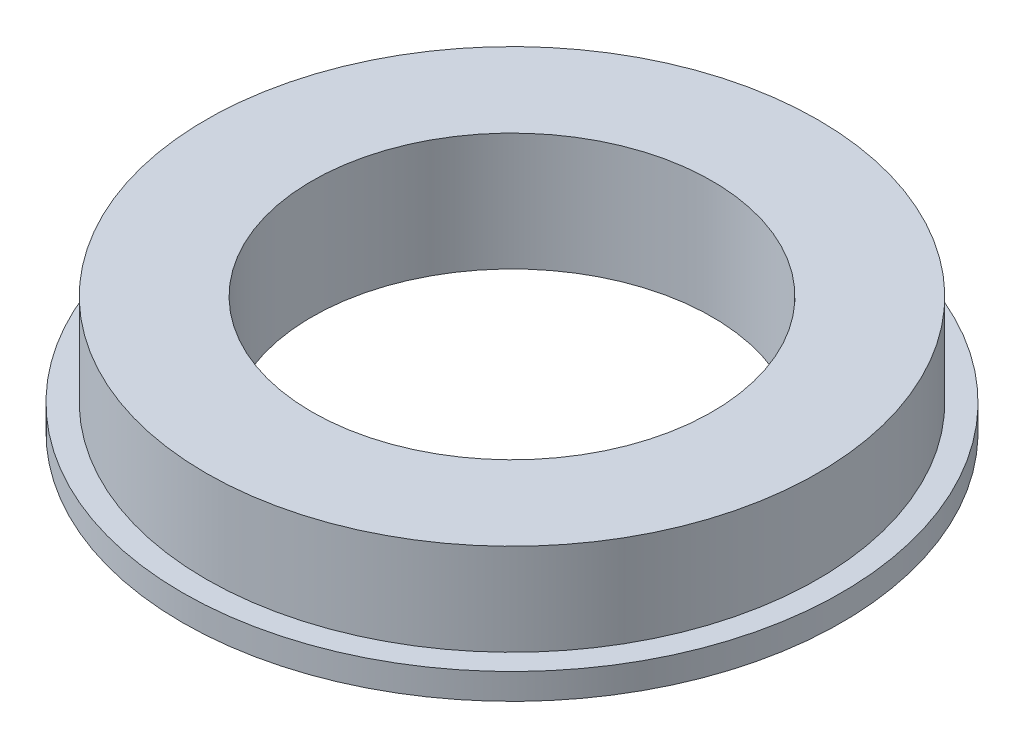
from build123d import *

# Parameters (mm, degrees)
SKETCH_2_R          = 14
EXTRUDE_1_DEPTH     = 1.1
SKETCH_3_R          = 13
EXTRUDE_2_DEPTH     = 3.9
SKETCH_4_R          = 8.5
CUT_EXTRUDE_1_DEPTH = 6


with BuildPart() as part:
    # 草图2 → 凸台-拉伸1 (new body)
    with BuildSketch(Plane(origin=(0, 0, 0), x_dir=(1, 0, 0), z_dir=(0, 1, 0))):
        Circle(SKETCH_2_R)
    extrude(amount=EXTRUDE_1_DEPTH)

    # 草图3 → 凸台-拉伸2 (add)
    with BuildSketch(Plane(origin=(0, 1.1, 0), x_dir=(1, 0, 0), z_dir=(0, 1, 0))):
        Circle(SKETCH_3_R)
    extrude(amount=EXTRUDE_2_DEPTH)

    # 草图4 → 切除-拉伸1 (cut, through all)
    with BuildSketch(Plane(origin=(0, 5, 0), x_dir=(1, 0, 0), z_dir=(0, 1, 0))):
        Circle(SKETCH_4_R)
    extrude(amount=-CUT_EXTRUDE_1_DEPTH, mode=Mode.SUBTRACT)


solid = part.part
